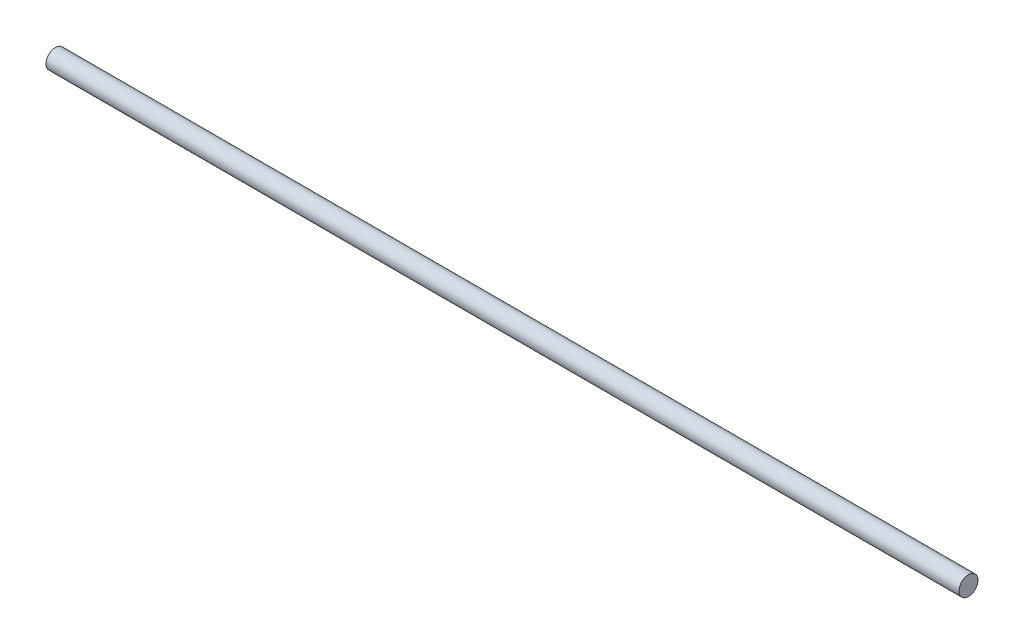
from build123d import *

# Parameters (mm, degrees)
SKETCH1_R           = 3.175
BOSS_EXTRUDE1_DEPTH = 304.8


with BuildPart() as part:
    # Sketch1 → Boss-Extrude1 (new body)
    with BuildSketch(Plane(origin=(0, 0, 0), x_dir=(0, 0, -1), z_dir=(1, 0, 0))):
        Circle(SKETCH1_R)
    extrude(amount=BOSS_EXTRUDE1_DEPTH)


solid = part.part
